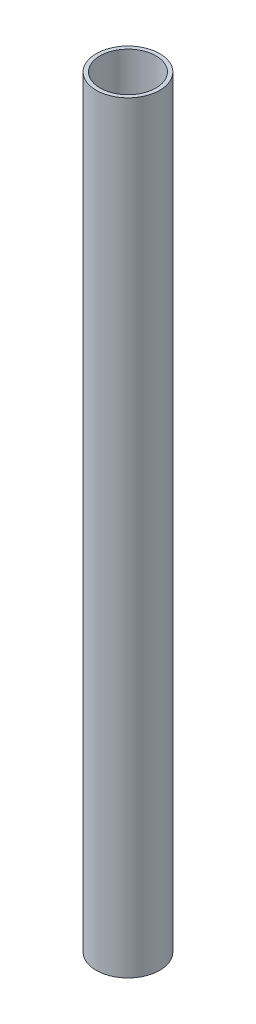
from build123d import *

# Parameters (mm, degrees)
SKETCH1_R           = 12.7
SKETCH1_R_2         = 11.176
BOSS_EXTRUDE1_DEPTH = 304.8


with BuildPart() as part:
    # Sketch1 → Boss-Extrude1 (new body)
    with BuildSketch(Plane(origin=(0, 0, 0), x_dir=(1, 0, 0), z_dir=(0, 1, 0))):
        Circle(SKETCH1_R)
        Circle(SKETCH1_R_2, mode=Mode.SUBTRACT)
    extrude(amount=BOSS_EXTRUDE1_DEPTH)


solid = part.part
